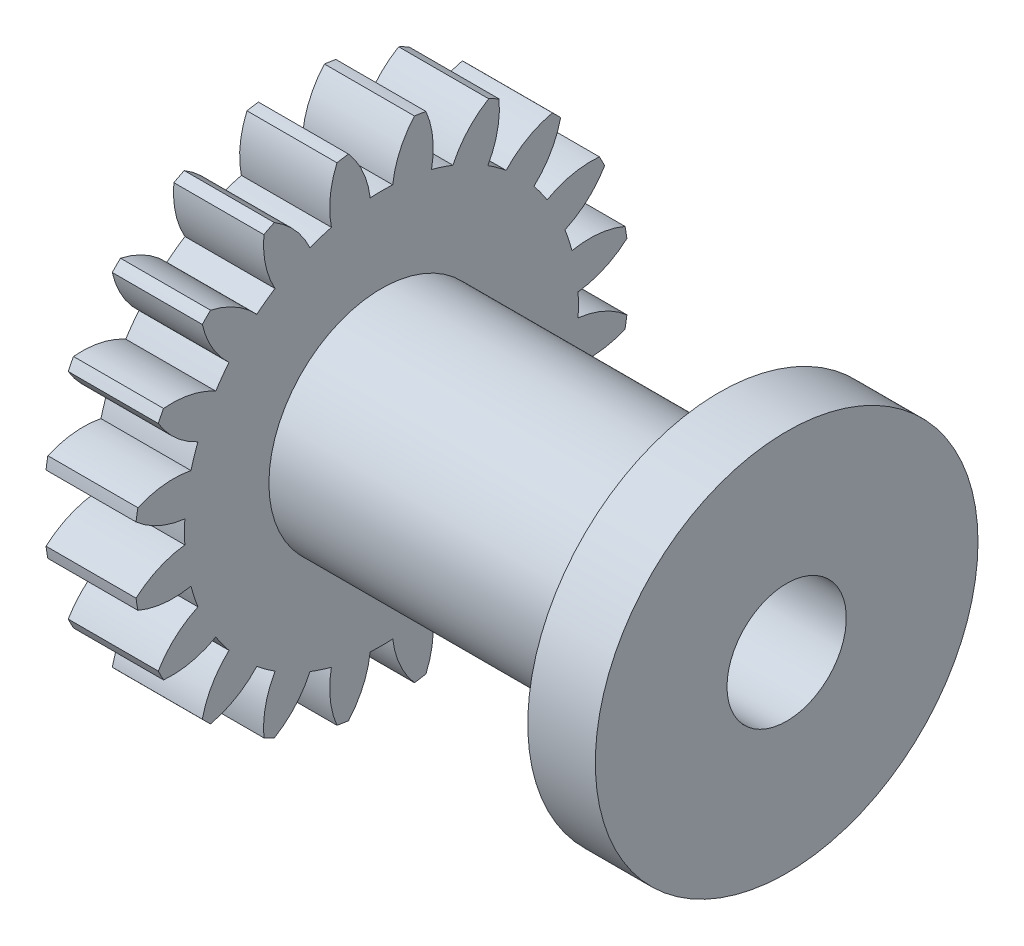
from build123d import *

# Parameters (mm, degrees)
BASPROSKE_W             = 4
BASPROSKE_H             = 11
TOOTHCUT_DEPTH          = 17.062378404
TEETHCUTS_COUNT         = 20
TEETHCUTS_ANGLE         = 342
BORSKE_R                = 2.5
BORE_DEPTH              = 50.0000508
SKETCH2_R               = 5
BOSS_EXTRUDE2_DEPTH     = 15
SKETCH3_R               = 8.5
BOSS_EXTRUDE3_DEPTH     = 3
SKETCH4_R               = 2.65
CUT_EXTRUDE1_DEPTH      = 27.864619954
CUT_EXTRUDE1_DEPTH_BACK = 27.864619954


with BuildPart() as part:
    # BasProSke → Base-Revolve (revolve)
    with BuildSketch(Plane(origin=(0, 0, 0), x_dir=(1, 0, 0), z_dir=(0, 1, 0)), mode=Mode.PRIVATE) as base_revolve_sk:
        with Locations((2, 5.5)):
            Rectangle(BASPROSKE_W, BASPROSKE_H)
    revolve(base_revolve_sk.sketch.rotate(Axis((-10, 0, 0), (1, 0, 0)), 180), axis=Axis((-10, 0, 0), (1, 0, 0)))

    # TooCutSke → ToothCut (cut, through all)
    with BuildSketch(Plane(origin=(0, 0, 0), x_dir=(0, 0, -1), z_dir=(1, 0, 0))):
        with BuildLine():
            ThreePointArc((0.499924007, 8.734705318), (0, 8.749), (-0.499924007, 8.734705318))
            ThreePointArc((-0.499924007, 8.734705318), (-0.824302243, 9.905497836), (-1.485192705, 10.924909509))
            ThreePointArc((-1.485192705, 10.924909509), (0, 11.0254), (1.485192705, 10.924909509))
            ThreePointArc((1.485192705, 10.924909509), (0.824302243, 9.905497836), (0.499924007, 8.734705318))
        make_face()
    toothcut = extrude(amount=TOOTHCUT_DEPTH, mode=Mode.SUBTRACT)

    # TeethCuts: ToothCut ×20 about axis
    teethcuts_axis = Axis((-10, 0, 0), (1, 0, 0))
    for i in range(1, TEETHCUTS_COUNT):
        add(toothcut.rotate(teethcuts_axis, i * TEETHCUTS_ANGLE / (TEETHCUTS_COUNT - 1)), mode=Mode.SUBTRACT)

    # BorSke → Bore (cut, symmetric)
    with BuildSketch(Plane(origin=(0, 0, 0), x_dir=(0, 0, -1), z_dir=(1, 0, 0))):
        with Locations(Location((0, 0, 0), (0, 0, 180))):
            Circle(BORSKE_R)
    extrude(amount=BORE_DEPTH, both=True, mode=Mode.SUBTRACT)

    # Sketch2 → Boss-Extrude2 (add)
    with BuildSketch(Plane(origin=(4, 0, 0), x_dir=(0, 0, -1), z_dir=(1, 0, 0))):
        with Locations(Location((0, 0, 0), (0, 0, 180))):
            Circle(SKETCH2_R)
    extrude(amount=BOSS_EXTRUDE2_DEPTH)

    # Sketch3 → Boss-Extrude3 (add)
    with BuildSketch(Plane(origin=(19, 0, 0), x_dir=(0, 0, -1), z_dir=(1, 0, 0))):
        Circle(SKETCH3_R)
    extrude(amount=BOSS_EXTRUDE3_DEPTH)

    # Sketch4 → Cut-Extrude1 (cut, two sides)
    with BuildSketch(Plane(origin=(22, 0, 0), x_dir=(0, 0, -1), z_dir=(1, 0, 0))) as cut_extrude1_sk:
        with Locations(Location((0, 0, 0), (0, 0, 180))):
            Circle(SKETCH4_R)
    extrude(amount=CUT_EXTRUDE1_DEPTH, mode=Mode.SUBTRACT)
    extrude(cut_extrude1_sk.sketch, amount=-CUT_EXTRUDE1_DEPTH_BACK, mode=Mode.SUBTRACT)


solid = part.part
